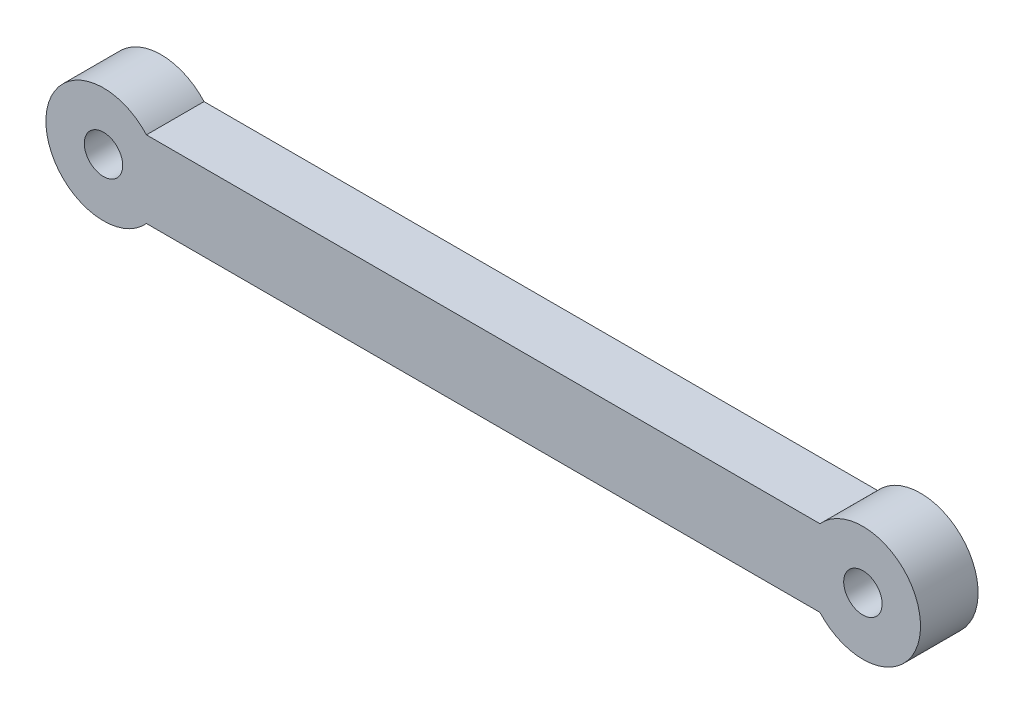
from build123d import *

# Parameters (mm, degrees)
SKETCH1_R           = 1
BOSS_EXTRUDE1_DEPTH = 3


with BuildPart() as part:
    # Sketch1 → Boss-Extrude1 (new body)
    with BuildSketch(Plane.XY):
        with BuildLine():
            Line((-41.402670324, 25.829974552), (-6.324806279, 25.829974552))
            ThreePointArc((-6.324806279, 25.829974552), (-1.088738302, 23.829974552), (-6.324806279, 21.829974552))
            Line((-6.324806279, 21.829974552), (-41.402670324, 21.829974552))
            ThreePointArc((-41.402670324, 21.829974552), (-46.638738302, 23.829974552), (-41.402670324, 25.829974552))
        make_face()
        with Locations((-4.088738302, 23.829974552)):
            Circle(SKETCH1_R, mode=Mode.SUBTRACT)
        with Locations((-43.638738302, 23.829974552)):
            Circle(SKETCH1_R, mode=Mode.SUBTRACT)
    extrude(amount=BOSS_EXTRUDE1_DEPTH)


solid = part.part
